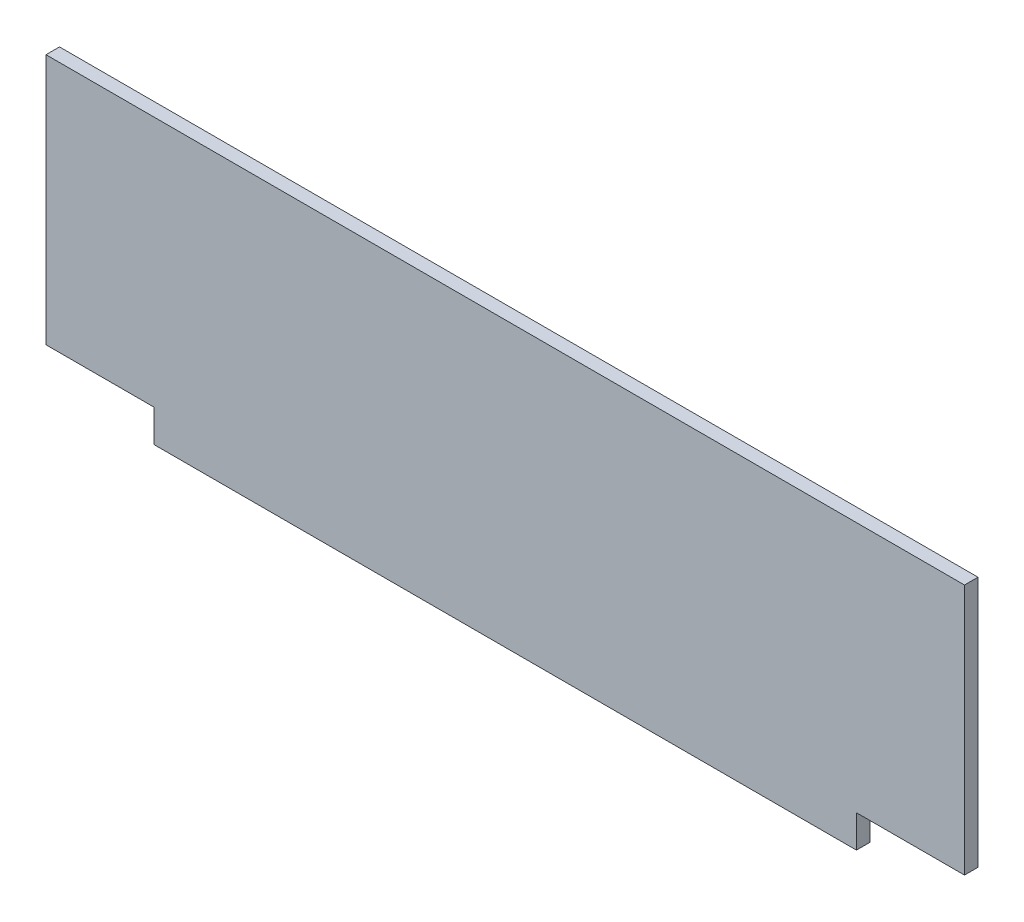
from build123d import *

# Parameters (mm, degrees)
ESQUISSE1_W             = 680
ESQUISSE1_H             = 210
BOSS_EXTRU_1_DEPTH      = 10
ESQUISSE2_W             = 80
ESQUISSE2_H             = 24
ENL_V_MAT_EXTRU_1_DEPTH = 11


with BuildPart() as part:
    # Esquisse1 → Boss.-Extru.1 (new body)
    with BuildSketch(Plane.XY):
        Rectangle(ESQUISSE1_W, ESQUISSE1_H)
    extrude(amount=BOSS_EXTRU_1_DEPTH)

    # Esquisse2 → Enlèv. mat.-Extru.1 (cut, through all)
    with BuildSketch(Plane.XY.offset(10)):
        with Locations((-300, -93)):
            Rectangle(ESQUISSE2_W, ESQUISSE2_H)
        with Locations((300, -93)):
            Rectangle(ESQUISSE2_W, ESQUISSE2_H)
    extrude(amount=-ENL_V_MAT_EXTRU_1_DEPTH, mode=Mode.SUBTRACT)


solid = part.part
